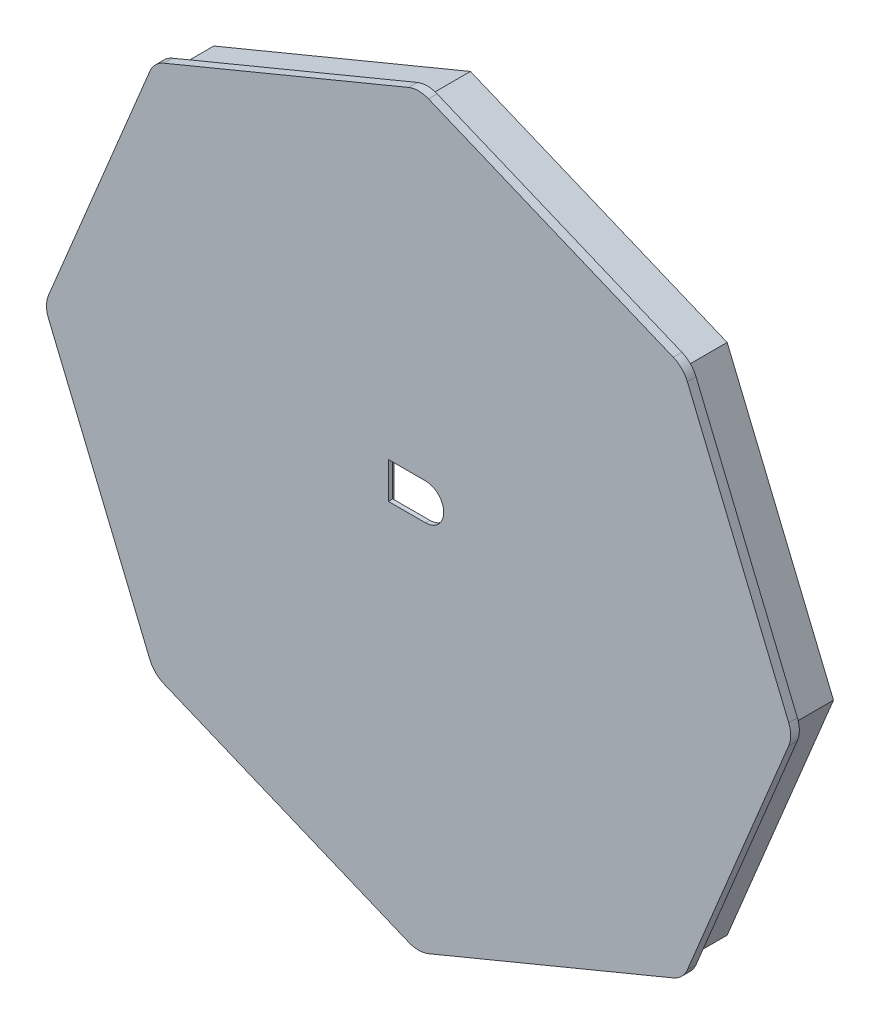
from build123d import *

# Parameters (mm, degrees)
BOSS_EXTRU_1_DEPTH      = 1
ENL_V_MAT_EXTRU_1_DEPTH = 1
BOSS_EXTRU_2_DEPTH      = 5
ESQUISSE4_W             = 8.8
ESQUISSE4_H             = 7.4
ENL_V_MAT_EXTRU_2_DEPTH = 0.5


with BuildPart() as part:
    # Esquisse1 → Boss.-Extru.1 (new body)
    with BuildSketch(Plane.XY):
        with BuildLine():
            Line((-19.325920559, 52.160343492), (-47.644494554, 40.430406076))
            ThreePointArc((-47.644494554, 40.430406076), (-48.617764601, 39.780087822), (-49.268082855, 38.806817776))
            Line((-49.268082855, 38.806817776), (-60.99802027, 10.488243781))
            ThreePointArc((-60.99802027, 10.488243781), (-61.226381673, 9.340193484), (-60.99802027, 8.192143187))
            Line((-60.99802027, 8.192143187), (-49.268082855, -20.126430808))
            ThreePointArc((-49.268082855, -20.126430808), (-48.617764601, -21.099700855), (-47.644494554, -21.750019109))
            Line((-47.644494554, -21.750019109), (-19.325920559, -33.479956525))
            ThreePointArc((-19.325920559, -33.479956525), (-18.177870262, -33.708317927), (-17.029819965, -33.479956525))
            Line((-17.029819965, -33.479956525), (11.28875403, -21.750019109))
            ThreePointArc((11.28875403, -21.750019109), (12.262024077, -21.099700855), (12.912342331, -20.126430808))
            Line((12.912342331, -20.126430808), (24.642279746, 8.192143187))
            ThreePointArc((24.642279746, 8.192143187), (24.870641149, 9.340193484), (24.642279746, 10.488243781))
            Line((24.642279746, 10.488243781), (12.912342331, 38.806817776))
            ThreePointArc((12.912342331, 38.806817776), (12.262024077, 39.780087822), (11.28875403, 40.430406076))
            Line((11.28875403, 40.430406076), (-17.029819965, 52.160343492))
            ThreePointArc((-17.029819965, 52.160343492), (-18.177870262, 52.388704894), (-19.325920559, 52.160343492))
        make_face()
    extrude(amount=BOSS_EXTRU_1_DEPTH)

    # Esquisse2 → Enlèv. mat.-Extru.1 (cut)
    with BuildSketch(Plane.XY.offset(1)):
        with BuildLine():
            Line((-21.671668776, 13.7151444), (-17.371668776, 13.7151444))
            ThreePointArc((-17.371668776, 13.7151444), (-15.271668776, 11.6151444), (-17.371668776, 9.5151444))
            Line((-17.371668776, 9.5151444), (-21.671668776, 9.5151444))
            Line((-21.671668776, 9.5151444), (-21.671668776, 13.7151444))
        make_face()
    extrude(amount=-ENL_V_MAT_EXTRU_1_DEPTH, mode=Mode.SUBTRACT)

    # Esquisse3 → Boss.-Extru.2 (add)
    with BuildSketch(Plane(origin=(0, 0, 0), x_dir=(-1, 0, 0), z_dir=(0, 0, -1))):
        Polygon((47.874104614, 39.036427835), (18.177870262, 51.337010855), (-11.51836409, 39.036427835), (-23.818947109, 9.340193484), (-11.51836409, -20.356040868), (18.177870262, -32.656623888), (47.874104614, -20.356040868), (60.174687633, 9.340193484), align=None)
        Polygon((47.108737749, 38.27106097), (18.177870262, 50.254618655), (-10.752997225, 38.27106097), (-22.736554909, 9.340193484), (-10.752997225, -19.590674003), (18.177870262, -31.574231687), (47.108737749, -19.590674003), (59.092295433, 9.340193484), align=None, mode=Mode.SUBTRACT)
    extrude(amount=BOSS_EXTRU_2_DEPTH)

    # Esquisse4 → Enlèv. mat.-Extru.2 (cut)
    with BuildSketch(Plane(origin=(0, 0, 0), x_dir=(-1, 0, 0), z_dir=(0, 0, -1))):
        with Locations((17.626428794, 11.6151444)):
            Rectangle(ESQUISSE4_W, ESQUISSE4_H)
    extrude(amount=-ENL_V_MAT_EXTRU_2_DEPTH, mode=Mode.SUBTRACT)


solid = part.part
